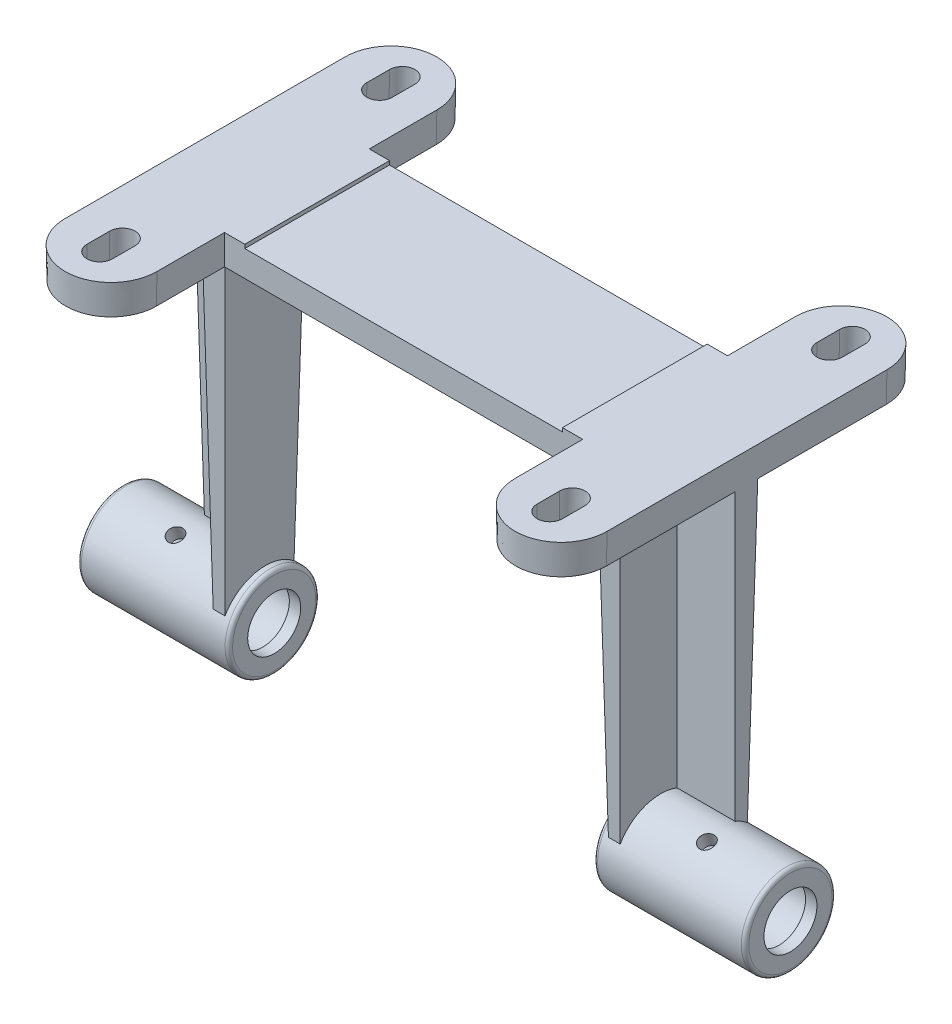
from build123d import *

# Parameters (mm, degrees)
BOSS_EXTRUDE1_DEPTH      = 12.7
BOSS_EXTRUDE1_DRAFT      = -1
SKETCH8_W                = 66.675
SKETCH8_H                = 1.5875
CUT_EXTRUDE1_DEPTH       = 139.494635157
CUT_EXTRUDE1_DEPTH_BACK  = 139.494635157
CUT_EXTRUDE3_REACH       = 227.639
CUT_EXTRUDE3_END_RADIUS  = 19.05
SKETCH9_R                = 3.175
BOSS_EXTRUDE2_REACH      = 228.521
BOSS_EXTRUDE2_END_RADIUS = 19.05
BOSS_EXTRUDE2_DRAFT      = 1


with BuildPart() as part:
    # Sketch2 → Boss-Extrude1 (with draft: the straight prism first)
    with BuildSketch(Plane(origin=(0, 0, 0), x_dir=(1, 0, 0), z_dir=(0, 1, 0))):
        with BuildLine():
            Line((-113.50625, 58.7375), (-113.50625, -58.7375))
            ThreePointArc((-113.50625, -58.7375), (-94.45625, -77.7875), (-75.40625, -58.7375))
            Line((-75.40625, -58.7375), (-75.40625, -30.1625))
            Line((-75.40625, -30.1625), (75.40625, -30.1625))
            Line((75.40625, -30.1625), (75.40625, -58.7375))
            ThreePointArc((75.40625, -58.7375), (94.45625, -77.7875), (113.50625, -58.7375))
            Line((113.50625, -58.7375), (113.50625, 58.7375))
            ThreePointArc((113.50625, 58.7375), (94.45625, 77.7875), (75.40625, 58.7375))
            Line((75.40625, 58.7375), (75.40625, 30.1625))
            Line((75.40625, 30.1625), (-75.40625, 30.1625))
            Line((-75.40625, 30.1625), (-75.40625, 58.7375))
            ThreePointArc((-75.40625, 58.7375), (-94.45625, 77.7875), (-113.50625, 58.7375))
        make_face()
        with BuildLine():
            ThreePointArc((-88.9, -63.5), (-94.45625, -69.05625), (-100.0125, -63.5))
            Line((-100.0125, -63.5), (-100.0125, -53.975))
            ThreePointArc((-100.0125, -53.975), (-94.45625, -48.41875), (-88.9, -53.975))
            Line((-88.9, -53.975), (-88.9, -63.5))
        make_face(mode=Mode.SUBTRACT)
        with BuildLine():
            Line((-100.0125, 53.975), (-100.0125, 63.5))
            ThreePointArc((-100.0125, 63.5), (-94.45625, 69.05625), (-88.9, 63.5))
            Line((-88.9, 63.5), (-88.9, 53.975))
            ThreePointArc((-88.9, 53.975), (-94.45625, 48.41875), (-100.0125, 53.975))
        make_face(mode=Mode.SUBTRACT)
        with BuildLine():
            Line((100.0125, 63.5), (100.0125, 53.975))
            ThreePointArc((100.0125, 53.975), (94.45625, 48.41875), (88.9, 53.975))
            Line((88.9, 53.975), (88.9, 63.5))
            ThreePointArc((88.9, 63.5), (94.45625, 69.05625), (100.0125, 63.5))
        make_face(mode=Mode.SUBTRACT)
        with BuildLine():
            Line((100.0125, -53.975), (100.0125, -63.5))
            ThreePointArc((100.0125, -63.5), (94.45625, -69.05625), (88.9, -63.5))
            Line((88.9, -63.5), (88.9, -53.975))
            ThreePointArc((88.9, -53.975), (94.45625, -48.41875), (100.0125, -53.975))
        make_face(mode=Mode.SUBTRACT)
    extrude(amount=BOSS_EXTRUDE1_DEPTH)
    # Boss-Extrude1: the draft: its side faces are tilted about the plane it starts from
    boss_extrude1_sides = [part.faces().sort_by_distance(p)[0] for p in [
        (-113.50625, 6.35, 0),
        (-94.45625, 6.35, 77.7875),
        (-75.40625, 6.35, 44.45),
        (0, 6.35, 30.1625),
        (75.40625, 6.35, 44.45),
        (94.45625, 6.35, 77.7875),
        (113.50625, 6.35, 0),
        (94.45625, 6.35, -77.7875),
        (75.40625, 6.35, -44.45),
        (0, 6.35, -30.1625),
        (-75.40625, 6.35, -44.45),
        (-94.45625, 6.35, -77.7875),
        (-94.45625, 6.35, 48.41875),
        (-88.9, 6.35, 58.7375),
        (-94.45625, 6.35, 69.05625),
        (-100.0125, 6.35, 58.7375),
        (-100.0125, 6.35, -58.7375),
        (-94.45625, 6.35, -69.05625),
        (-88.9, 6.35, -58.7375),
        (-94.45625, 6.35, -48.41875),
        (100.0125, 6.35, -58.7375),
        (94.45625, 6.35, -48.41875),
        (88.9, 6.35, -58.7375),
        (94.45625, 6.35, -69.05625),
        (100.0125, 6.35, 58.7375),
        (94.45625, 6.35, 69.05625),
        (88.9, 6.35, 58.7375),
        (94.45625, 6.35, 48.41875),
    ]]
    draft(boss_extrude1_sides, Plane(origin=(0, 0, 0), x_dir=(1, 0, 0), z_dir=(0, 1, 0)), BOSS_EXTRUDE1_DRAFT)

    # Sketch8 → Cut-Extrude1 (cut, two sides)
    with BuildSketch(Plane.XY) as cut_extrude1_sk:
        with Locations((-33.3375, 11.90625)):
            Rectangle(SKETCH8_W, SKETCH8_H)
        with Locations((33.3375, 11.90625)):
            Rectangle(SKETCH8_W, SKETCH8_H)
    extrude(amount=CUT_EXTRUDE1_DEPTH, mode=Mode.SUBTRACT)
    extrude(cut_extrude1_sk.sketch, amount=-CUT_EXTRUDE1_DEPTH_BACK, mode=Mode.SUBTRACT)



with BuildPart() as body_2:
    # Sketch5 → Revolve2 (revolve)
    with BuildSketch(Plane.XY.offset(9.525), mode=Mode.PRIVATE) as revolve2_sk:
        with BuildLine():
            Line((141.509179325, -122.2375), (141.509179325, -128.5748))
            Line((141.509179325, -128.5748), (136.746679325, -128.5748))
            Line((136.746679325, -128.5748), (136.746679325, -126.20625))
            Line((136.746679325, -126.20625), (82.771679325, -126.20625))
            Line((82.771679325, -126.20625), (82.771679325, -128.5748))
            Line((82.771679325, -128.5748), (78.009179325, -128.5748))
            Line((78.009179325, -128.5748), (78.009179325, -122.2375))
            ThreePointArc((78.009179325, -122.2375), (78.474147309, -121.114967985), (79.596679325, -120.65))
            Line((79.596679325, -120.65), (139.921679325, -120.65))
            ThreePointArc((139.921679325, -120.65), (141.04421134, -121.114967985), (141.509179325, -122.2375))
        make_face()
        with BuildLine():
            Line((-138.684570675, -128.5748), (-138.684570675, -122.2375))
            ThreePointArc((-138.684570675, -122.2375), (-138.219602691, -121.114967985), (-137.097070675, -120.65))
            Line((-137.097070675, -120.65), (-76.772070675, -120.65))
            ThreePointArc((-76.772070675, -120.65), (-75.64953866, -121.114967985), (-75.184570675, -122.2375))
            Line((-75.184570675, -122.2375), (-75.184570675, -128.5748))
            Line((-75.184570675, -128.5748), (-79.947070675, -128.5748))
            Line((-79.947070675, -128.5748), (-79.947070675, -126.20625))
            Line((-79.947070675, -126.20625), (-133.922070675, -126.20625))
            Line((-133.922070675, -126.20625), (-133.922070675, -128.5748))
            Line((-133.922070675, -128.5748), (-138.684570675, -128.5748))
        make_face()
    revolve(revolve2_sk.sketch.rotate(Axis((-113.50625, -139.7, 9.525), (1, 0, 0)), 90), axis=Axis((-113.50625, -139.7, 9.525), (1, 0, 0)))

    # Cut-Extrude3: up to this cylinder (the profile starts inside it)
    cut_extrude3_end = Plane(origin=(1.412304, -139.7, 9.525), z_dir=(-1, 0, 0)) * Cylinder(CUT_EXTRUDE3_END_RADIUS, 717.42175, mode=Mode.PRIVATE)
    # Sketch9 → Cut-Extrude3 (cut, up to the surface)
    with BuildSketch(Plane(origin=(0, -139.7, 9.525), x_dir=(1, 0, 0), z_dir=(0, 0.9396926207859079, 0.3420201433256704)), mode=Mode.PRIVATE) as cut_extrude3_sk1:
        with Locations(Location((-110.109570675, 0, 0), (0, 0, 90))):
            Circle(SKETCH9_R)
    cut_extrude3_tool1 = extrude(cut_extrude3_sk1.sketch, amount=CUT_EXTRUDE3_REACH, mode=Mode.PRIVATE) & cut_extrude3_end
    add(cut_extrude3_tool1.solids().sort_by_distance((-110.109571, -139.7, 9.525))[0], mode=Mode.SUBTRACT)
    # Sketch9 → Cut-Extrude3 (cut, up to the surface)
    with BuildSketch(Plane(origin=(0, -139.7, 9.525), x_dir=(1, 0, 0), z_dir=(0, 0.9396926207859079, 0.3420201433256704)), mode=Mode.PRIVATE) as cut_extrude3_sk2:
        with Locations(Location((112.934179325, 0, 0), (0, 0, 90))):
            Circle(SKETCH9_R)
    cut_extrude3_tool2 = extrude(cut_extrude3_sk2.sketch, amount=CUT_EXTRUDE3_REACH, mode=Mode.PRIVATE) & cut_extrude3_end
    add(cut_extrude3_tool2.solids().sort_by_distance((112.934179, -139.7, 9.525))[0], mode=Mode.SUBTRACT)


with BuildPart() as part_1:
    add(part.part)

    add(body_2.part)  # Boss-Extrude2 merges body 2
    # Boss-Extrude2: up to this cylinder (the profile starts outside it)
    boss_extrude2_end = Plane(origin=(8.945782, -139.7, 9.525), z_dir=(-1, 0, 0)) * Cylinder(BOSS_EXTRUDE2_END_RADIUS, 704.311884, mode=Mode.PRIVATE)



with BuildPart() as boss_extrude2_long_prism_1:
    # Sketch6 → Boss-Extrude2 (the long prism of profile 1, to be tilted and cut off)
    with BuildSketch(Plane(origin=(0, 0, 0), x_dir=(-1, 0, 0), z_dir=(0, -1, 0))):
        Polygon((113.50625, 4.7625), (76.772070675, 4.7625), (76.772070675, -28.575), (86.297070675, -28.575), (86.297070675, -4.7625), (113.50625, -4.7625), align=None)
    extrude(amount=BOSS_EXTRUDE2_REACH)
    boss_extrude2_tool1_sides = [boss_extrude2_long_prism_1.faces().sort_by_distance(p)[0] for p in [
        (-95.139160338, -114.2605, -4.7625),
        (-76.772070675, -114.2605, 11.90625),
        (-81.534570675, -114.2605, 28.575),
        (-86.297070675, -114.2605, 16.66875),
        (-99.901660338, -114.2605, 4.7625),
        (-113.50625, -114.2605, 0),
    ]]
    draft(boss_extrude2_tool1_sides, Plane(origin=(0, 0, 0), x_dir=(-1, 0, 0), z_dir=(0, -1, 0)), BOSS_EXTRUDE2_DRAFT)  # the draft: side faces tilted about the start plane


with BuildPart() as part_2:
    add(part_1.part)
    boss_extrude2_tool1 = boss_extrude2_long_prism_1.part - boss_extrude2_end
    add(boss_extrude2_tool1.solids().sort_by_distance((-95.13916, 0, -4.266437))[0])



with BuildPart() as boss_extrude2_long_prism_2:
    # Sketch6 → Boss-Extrude2 (the long prism of profile 2, to be tilted and cut off)
    with BuildSketch(Plane(origin=(0, 0, 0), x_dir=(-1, 0, 0), z_dir=(0, -1, 0))):
        Polygon((-113.50625, -4.7625), (-113.50625, 4.7625), (-79.596679325, 4.7625), (-79.596679325, -28.575), (-89.121679325, -28.575), (-89.121679325, -4.7625), align=None)
    extrude(amount=BOSS_EXTRUDE2_REACH)
    boss_extrude2_tool2_sides = [boss_extrude2_long_prism_2.faces().sort_by_distance(p)[0] for p in [
        (113.50625, -114.2605, 0),
        (96.551464662, -114.2605, -4.7625),
        (79.596679325, -114.2605, 11.90625),
        (84.359179325, -114.2605, 28.575),
        (89.121679325, -114.2605, 16.66875),
        (101.313964662, -114.2605, 4.7625),
    ]]
    draft(boss_extrude2_tool2_sides, Plane(origin=(0, 0, 0), x_dir=(-1, 0, 0), z_dir=(0, -1, 0)), BOSS_EXTRUDE2_DRAFT)  # the draft: side faces tilted about the start plane


with BuildPart() as part_3:
    add(part_2.part)
    boss_extrude2_tool2 = boss_extrude2_long_prism_2.part - boss_extrude2_end
    add(boss_extrude2_tool2.solids().sort_by_distance((113.030724, 0, 0))[0])


solid = part_3.part
